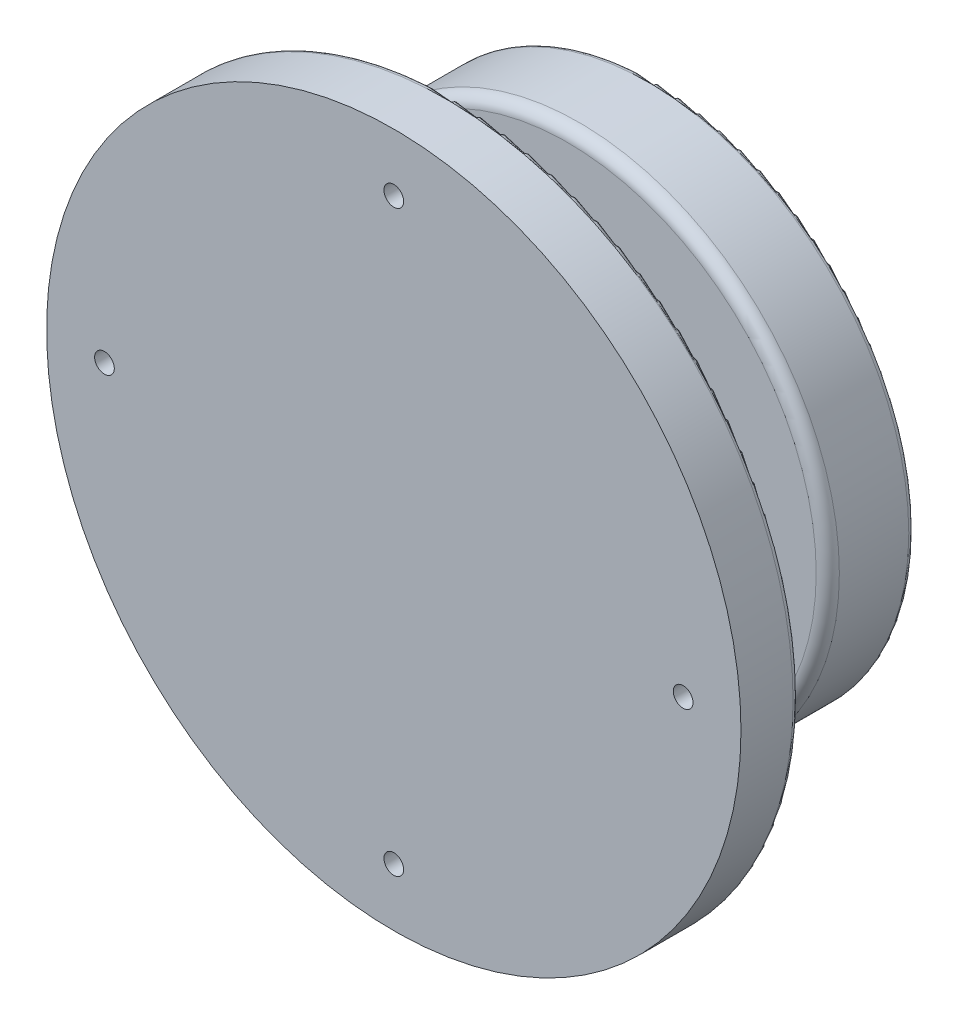
from build123d import *

# Parameters (mm, degrees)
ESQUISSE1_R                                = 45
BOSS_EXTRU_1_DEPTH                         = 15
ESQUISSE3_R                                = 10
BOSS_EXTRU_2_DEPTH                         = 20
ESQUISSE4_R                                = 60
BOSS_EXTRU_3_DEPTH                         = 10
CONG_1_R                                   = 2
CONG_2_R                                   = 1
CONG_3_R                                   = 1
TROU_TARAUD_M31_D                          = 2.5
TROU_TARAUD_M31_DEPTH                      = 12.5
TROU_TARAUD_M31_TIP                        = 0.751075774
CHAMBRAGE_POUR_VIS_T_TE_HEXAGONALE_2_COUNT = 2
CHAMBRAGE_POUR_VIS_T_TE_HEXAGONALE_2_PITCH = 70.710678119
CHAMBRAGE_POUR_VIS_T_TE_HEXAGONALE_3_COUNT = 2
CHAMBRAGE_POUR_VIS_T_TE_HEXAGONALE_3_PITCH = 100
CHAMBRAGE_POUR_VIS_T_TE_HEXAGONALE_4_COUNT = 2
CHAMBRAGE_POUR_VIS_T_TE_HEXAGONALE_4_PITCH = 70.710678119


with BuildPart() as part:
    # Esquisse1 → Boss.-Extru.1 (new body)
    with BuildSketch(Plane.XY):
        Circle(ESQUISSE1_R)
    extrude(amount=BOSS_EXTRU_1_DEPTH)

    # Esquisse3 → Boss.-Extru.2 (add)
    with BuildSketch(Plane.XY.offset(15)):
        Circle(ESQUISSE3_R)
    extrude(amount=BOSS_EXTRU_2_DEPTH)

    # Esquisse4 → Boss.-Extru.3 (add)
    with BuildSketch(Plane.XY.offset(35)):
        Circle(ESQUISSE4_R)
    extrude(amount=BOSS_EXTRU_3_DEPTH)

    # Congé1
    cong_1_edges = [part.edges().sort_by_distance(p)[0] for p in [
        (-45, 0, 15),
    ]]
    fillet(cong_1_edges, radius=CONG_1_R)

    # Congé2
    cong_2_edges = [part.edges().sort_by_distance(p)[0] for p in [
        (-60, 0, 35),
    ]]
    fillet(cong_2_edges, radius=CONG_2_R)

    # Congé3
    cong_3_edges = [part.edges().sort_by_distance(p)[0] for p in [
        (-45, 0, 0),
    ]]
    fillet(cong_3_edges, radius=CONG_3_R)

    # Trou taraudé M31
    with Locations(Plane(origin=(-7, 0, 0), x_dir=(-1, 0, 0), z_dir=(0, 0, -1))):
        with Locations((0, 0), (-14, 0)):
            Hole(TROU_TARAUD_M31_D / 2, depth=TROU_TARAUD_M31_DEPTH)
            with Locations((0, 0, -(TROU_TARAUD_M31_DEPTH + TROU_TARAUD_M31_TIP / 2))):  # 118° drill point
                Cone(0, TROU_TARAUD_M31_D / 2, TROU_TARAUD_M31_TIP, mode=Mode.SUBTRACT)

    # Esquisse9 → Chambrage pour vis à tête hexagonale M31 (revolve, cut)
    with BuildSketch(Plane(origin=(0, 50, 35), x_dir=(0, 1, 0), z_dir=(1, 0, 0))):
        Polygon((0, 0), (0, 10), (1.7, 10), (1.7, 5), (4.6755, 5), (4.6755, 0.025), (4.7005, 0), align=None)
    chambrage_pour_vis_t_te_hexagonale_m31 = revolve(axis=Axis((0, 50, 28.65), (0, 0, 1)), mode=Mode.SUBTRACT)

    # Chambrage pour vis _ t_te hexagonale 2: Chambrage pour vis à tête hexagonale M31 ×2
    with Locations(*[Vector(0.707106781, -0.707106781, 0) * (i * CHAMBRAGE_POUR_VIS_T_TE_HEXAGONALE_2_PITCH) for i in range(1, CHAMBRAGE_POUR_VIS_T_TE_HEXAGONALE_2_COUNT)]):
        add(chambrage_pour_vis_t_te_hexagonale_m31, mode=Mode.SUBTRACT)

    # Chambrage pour vis _ t_te hexagonale 3: Chambrage pour vis à tête hexagonale M31 ×2
    with Locations(*[(0, -i * CHAMBRAGE_POUR_VIS_T_TE_HEXAGONALE_3_PITCH, 0) for i in range(1, CHAMBRAGE_POUR_VIS_T_TE_HEXAGONALE_3_COUNT)]):
        add(chambrage_pour_vis_t_te_hexagonale_m31, mode=Mode.SUBTRACT)

    # Chambrage pour vis _ t_te hexagonale 4: Chambrage pour vis à tête hexagonale M31 ×2
    with Locations(*[Vector(-0.707106781, -0.707106781, 0) * (i * CHAMBRAGE_POUR_VIS_T_TE_HEXAGONALE_4_PITCH) for i in range(1, CHAMBRAGE_POUR_VIS_T_TE_HEXAGONALE_4_COUNT)]):
        add(chambrage_pour_vis_t_te_hexagonale_m31, mode=Mode.SUBTRACT)


solid = part.part
